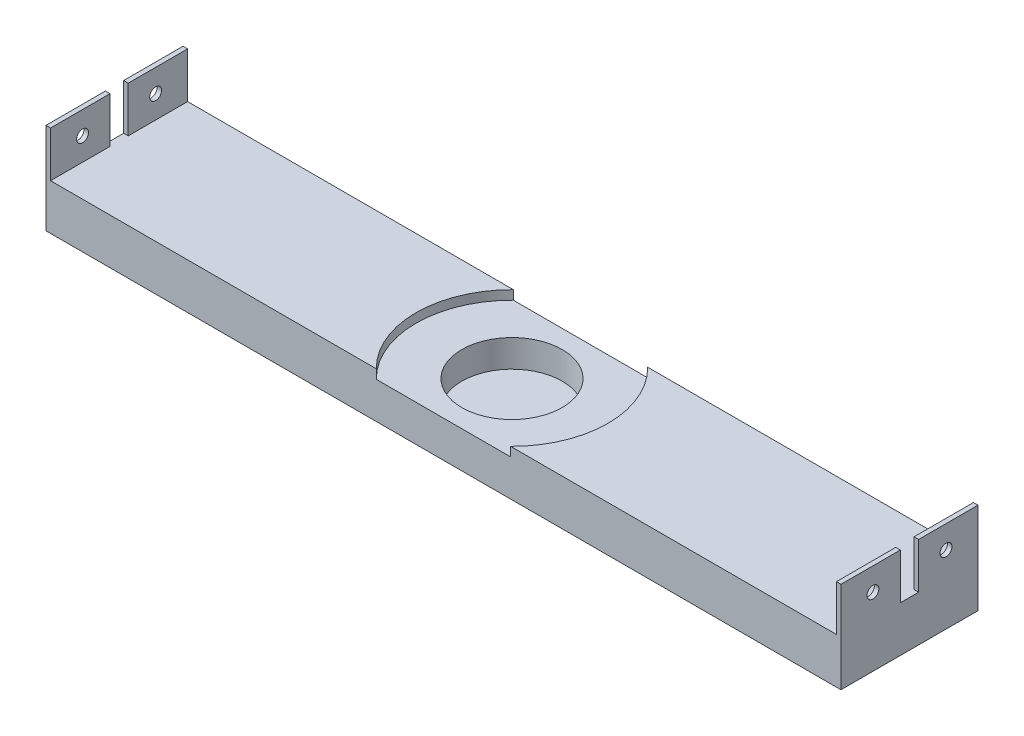
from build123d import *

# Parameters (mm, degrees)
BOSS_EXTRUDE1_DEPTH     = 30
SKETCH2_R               = 11
CUT_EXTRUDE1_DEPTH      = 8
SKETCH3_R               = 1.3
CUT_EXTRUDE2_DEPTH      = 1
CUT_EXTRUDE2_DEPTH_BACK = 175
SKETCH4_W               = 4
SKETCH4_H               = 10
CUT_EXTRUDE3_DEPTH      = 1
CUT_EXTRUDE3_DEPTH_BACK = 175
SKETCH5_R               = 21
CUT_EXTRUDE4_DEPTH      = 2


with BuildPart() as part:
    # Sketch1 → Boss-Extrude1 (new body)
    with BuildSketch(Plane.XY):
        Polygon((-87, 20), (-87, 0), (87, 0), (87, 20), (86, 20), (86, 10), (-86, 10), (-86, 20), align=None)
    extrude(amount=BOSS_EXTRUDE1_DEPTH)

    # Sketch2 → Cut-Extrude1 (cut)
    with BuildSketch(Plane(origin=(0, 10, 0), x_dir=(1, 0, 0), z_dir=(0, 1, 0))):
        with Locations((0, -15)):
            Circle(SKETCH2_R)
    extrude(amount=-CUT_EXTRUDE1_DEPTH, mode=Mode.SUBTRACT)

    # Sketch3 → Cut-Extrude2 (cut, two sides)
    with BuildSketch(Plane(origin=(87, 0, 0), x_dir=(0, 0, -1), z_dir=(1, 0, 0))) as cut_extrude2_sk:
        with Locations((-23, 15)):
            Circle(SKETCH3_R)
        with Locations((-7, 15)):
            Circle(SKETCH3_R)
    extrude(amount=CUT_EXTRUDE2_DEPTH, mode=Mode.SUBTRACT)
    extrude(cut_extrude2_sk.sketch, amount=-CUT_EXTRUDE2_DEPTH_BACK, mode=Mode.SUBTRACT)

    # Sketch4 → Cut-Extrude3 (cut, two sides)
    with BuildSketch(Plane.ZY.offset(87)) as cut_extrude3_sk:
        with Locations((15, 15)):
            Rectangle(SKETCH4_W, SKETCH4_H)
    extrude(amount=CUT_EXTRUDE3_DEPTH, mode=Mode.SUBTRACT)
    extrude(cut_extrude3_sk.sketch, amount=-CUT_EXTRUDE3_DEPTH_BACK, mode=Mode.SUBTRACT)

    # Sketch5 → Cut-Extrude4 (cut)
    with BuildSketch(Plane(origin=(0, 10, 0), x_dir=(1, 0, 0), z_dir=(0, 1, 0))):
        with Locations((0, -15)):
            Circle(SKETCH5_R)
    extrude(amount=-CUT_EXTRUDE4_DEPTH, mode=Mode.SUBTRACT)


solid = part.part
